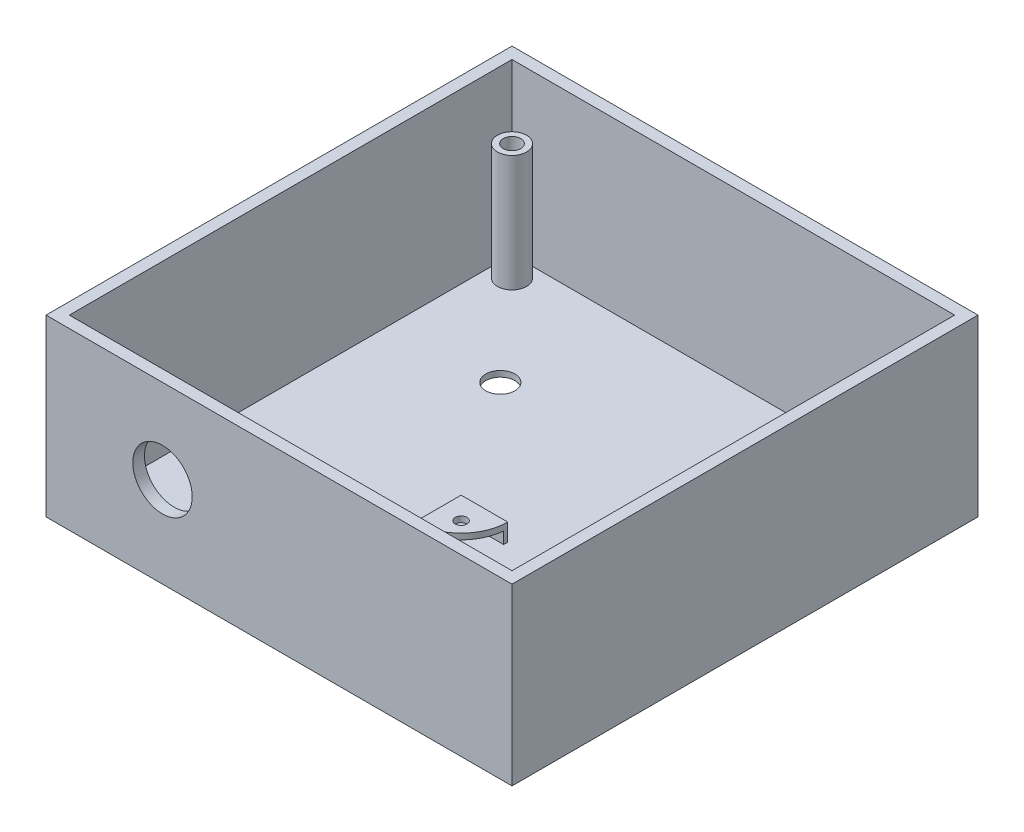
from build123d import *

# Parameters (mm, degrees)
SKETCH1_W           = 80
SKETCH1_H           = 80
BOSS_EXTRUDE1_DEPTH = 30
SKETCH2_W           = 76
SKETCH2_H           = 76
CUT_EXTRUDE1_DEPTH  = 29
SKETCH3_R           = 2.5
SKETCH3_R_2         = 1.5
BOSS_EXTRUDE5_DEPTH = 20
SKETCH4_R           = 2.5
CUT_EXTRUDE2_DEPTH  = 10
SKETCH5_W           = 26.5
SKETCH5_H           = 15.5
CUT_EXTRUDE3_DEPTH  = 25
SKETCH6_R           = 5.1
CUT_EXTRUDE4_DEPTH  = 10
BOSS_EXTRUDE6_DEPTH = 3
CUT_EXTRUDE5_DEPTH  = 2
SKETCH10_R          = 1
CUT_EXTRUDE6_DEPTH  = 3


with BuildPart() as part:
    # Sketch1 → Boss-Extrude1 (new body)
    with BuildSketch(Plane(origin=(0, 0, 0), x_dir=(1, 0, 0), z_dir=(0, 1, 0))):
        Rectangle(SKETCH1_W, SKETCH1_H)
    extrude(amount=BOSS_EXTRUDE1_DEPTH)

    # Sketch2 → Cut-Extrude1 (cut)
    with BuildSketch(Plane(origin=(0, 30, 0), x_dir=(1, 0, 0), z_dir=(0, 1, 0))):
        Rectangle(SKETCH2_W, SKETCH2_H)
    extrude(amount=-CUT_EXTRUDE1_DEPTH, mode=Mode.SUBTRACT)

    # Sketch3 → Boss-Extrude5 (add)
    with BuildSketch(Plane(origin=(0, 1, 0), x_dir=(1, 0, 0), z_dir=(0, 1, 0))):
        with Locations((-34.5, 34.5)):
            Circle(SKETCH3_R)
        with Locations((-34.5, 34.5)):
            Circle(SKETCH3_R_2, mode=Mode.SUBTRACT)
        with Locations((34.5, 34.5)):
            Circle(SKETCH3_R)
        with Locations((34.5, 34.5)):
            Circle(SKETCH3_R_2, mode=Mode.SUBTRACT)
        with Locations((-34.5, -34.5)):
            Circle(SKETCH3_R)
        with Locations((-34.5, -34.5)):
            Circle(SKETCH3_R_2, mode=Mode.SUBTRACT)
        with Locations((34.5, -34.5)):
            Circle(SKETCH3_R)
        with Locations((34.5, -34.5)):
            Circle(SKETCH3_R_2, mode=Mode.SUBTRACT)
    extrude(amount=BOSS_EXTRUDE5_DEPTH)

    # Sketch4 → Cut-Extrude2 (cut)
    with BuildSketch(Plane.XZ):
        with Locations((-20, -18)):
            Circle(SKETCH4_R)
    extrude(amount=-CUT_EXTRUDE2_DEPTH, mode=Mode.SUBTRACT)

    # Sketch5 → Cut-Extrude3 (cut)
    with BuildSketch(Plane.XZ):
        with Locations((11.75, 22.941412849)):
            Rectangle(SKETCH5_W, SKETCH5_H)
    extrude(amount=-CUT_EXTRUDE3_DEPTH, mode=Mode.SUBTRACT)

    # Sketch6 → Cut-Extrude4 (cut)
    with BuildSketch(Plane.XY.offset(40)):
        with Locations((-20, 15.536781198)):
            Circle(SKETCH6_R)
    extrude(amount=-CUT_EXTRUDE4_DEPTH, mode=Mode.SUBTRACT)

    # Sketch11 → Boss-Extrude6 (add)
    with BuildSketch(Plane(origin=(0, 1, 0), x_dir=(1, 0, 0), z_dir=(0, 1, 0))):
        with BuildLine():
            Line((-3.6, -5.131412849), (-3.6, -13.131412849))
            ThreePointArc((-3.6, -13.131412849), (2.056854249, -10.788267099), (4.4, -5.131412849))
            Line((4.4, -5.131412849), (-3.6, -5.131412849))
        make_face()
        with BuildLine():
            Line((19.1, -5.131412849), (27.1, -5.131412849))
            Line((27.1, -5.131412849), (27.1, -13.131412849))
            ThreePointArc((27.1, -13.131412849), (21.443145751, -10.788267099), (19.1, -5.131412849))
        make_face()
        with BuildLine():
            Line((27.1, -28.491412849), (27.1, -36.491412849))
            Line((27.1, -36.491412849), (19.1, -36.491412849))
            ThreePointArc((19.1, -36.491412849), (21.443145751, -30.8345586), (27.1, -28.491412849))
        make_face()
        with BuildLine():
            Line((4.4, -36.491412849), (-3.6, -36.491412849))
            Line((-3.6, -36.491412849), (-3.6, -28.491412849))
            ThreePointArc((-3.6, -28.491412849), (2.056854249, -30.8345586), (4.4, -36.491412849))
        make_face()
    extrude(amount=BOSS_EXTRUDE6_DEPTH)

    # Sketch12 → Cut-Extrude5 (cut)
    with BuildSketch(Plane(origin=(0, 1, 0), x_dir=(1, 0, 0), z_dir=(0, 1, 0))):
        with BuildLine():
            Line((-2.9, -13.100729005), (-2.9, -5.831412849))
            Line((-2.9, -5.831412849), (4.369316156, -5.831412849))
            ThreePointArc((4.369316156, -5.831412849), (2.240182749, -10.971595598), (-2.9, -13.100729005))
        make_face()
        with BuildLine():
            Line((19.130683844, -5.831412849), (26.4, -5.831412849))
            Line((26.4, -5.831412849), (26.4, -13.100729005))
            ThreePointArc((26.4, -13.100729005), (21.259817251, -10.971595598), (19.130683844, -5.831412849))
        make_face()
        with BuildLine():
            Line((26.4, -35.491412849), (26.4, -28.522096693))
            ThreePointArc((26.4, -28.522096693), (21.471949286, -30.563362135), (19.430683844, -35.491412849))
            Line((19.430683844, -35.491412849), (26.4, -35.491412849))
        make_face()
        with BuildLine():
            Line((4.337253933, -35.491412849), (-2.9, -35.491412849))
            Line((-2.9, -35.491412849), (-2.9, -28.254158916))
            ThreePointArc((-2.9, -28.254158916), (2.217511333, -30.373901516), (4.337253933, -35.491412849))
        make_face()
    extrude(amount=CUT_EXTRUDE5_DEPTH, mode=Mode.SUBTRACT)

    # Sketch10 → Cut-Extrude6 (cut)
    with BuildSketch(Plane(origin=(0, 1, 0), x_dir=(1, 0, 0), z_dir=(0, 1, 0))):
        with Locations((0.2, -8.931412849)):
            Circle(SKETCH10_R)
        with Locations((23.3, -8.931412849)):
            Circle(SKETCH10_R)
        with Locations((0.2, -33.191412849)):
            Circle(SKETCH10_R)
        with Locations((23.3, -33.191412849)):
            Circle(SKETCH10_R)
    extrude(amount=CUT_EXTRUDE6_DEPTH, mode=Mode.SUBTRACT)


solid = part.part
